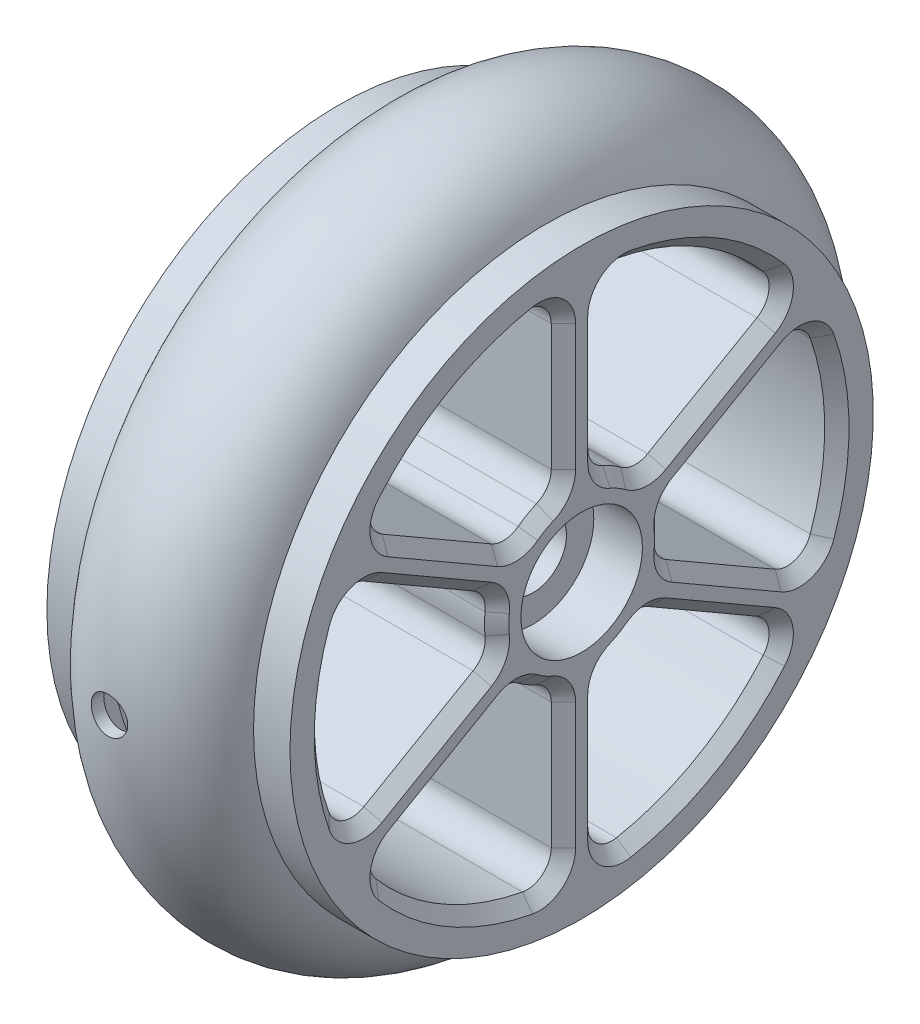
from build123d import *

# Parameters (mm, degrees)
CUT_EXTRUDE1_REACH = 22
SKETCH2_R          = 2.75
SKETCH3_R          = 5
CUT_EXTRUDE2_DEPTH = 4
SKETCH4_R          = 5
CUT_EXTRUDE3_DEPTH = 4
CUT_EXTRUDE4_REACH = 22
FILLET2_R          = 2
CHAMFER1_SIZE      = 1
CUT_EXTRUDE6_START = 5.94636
SKETCH9_R          = 1.5
CUT_EXTRUDE6_DEPTH = 8.05364
SKETCH7_R          = 5
CUT_EXTRUDE5_DEPTH = 0.5


with BuildPart() as part:
    # Sketch1 → Revolve1 (revolve)
    with BuildSketch(Plane.XY):
        with BuildLine():
            Line((-10, 24), (-10, 0))
            Line((-10, 0), (10, 0))
            Line((10, 0), (10, 24))
            Line((10, 24), (7, 24))
            ThreePointArc((7, 24), (0, 29), (-7, 24))
            Line((-7, 24), (-10, 24))
        make_face()
    revolve(axis=Axis((-29.685693942, 0, 0), (1, 0, 0)))

    # Sketch2 → Cut-Extrude1 (cut, up to next)
    with BuildSketch(Plane(origin=(10, 0, 0), x_dir=(0, 0, -1), z_dir=(1, 0, 0)), mode=Mode.PRIVATE) as cut_extrude1_sk1:
        Circle(SKETCH2_R)
    cut_extrude1_tool1 = extrude(cut_extrude1_sk1.sketch, amount=-CUT_EXTRUDE1_REACH, mode=Mode.PRIVATE) & part.part
    add(cut_extrude1_tool1.solids().sort_by_distance((10, 0, 0))[0], mode=Mode.SUBTRACT)

    # Sketch3 → Cut-Extrude2 (cut)
    with BuildSketch(Plane.ZY.offset(10)):
        Circle(SKETCH3_R)
    extrude(amount=-CUT_EXTRUDE2_DEPTH, mode=Mode.SUBTRACT)

    # Sketch4 → Cut-Extrude3 (cut)
    with BuildSketch(Plane(origin=(10, 0, 0), x_dir=(0, 0, -1), z_dir=(1, 0, 0))):
        Circle(SKETCH4_R)
    extrude(amount=-CUT_EXTRUDE3_DEPTH, mode=Mode.SUBTRACT)

    # Sketch5 → Cut-Extrude4 (cut, up to next)
    with BuildSketch(Plane(origin=(10, 0, 0), x_dir=(0, 0, -1), z_dir=(1, 0, 0)), mode=Mode.PRIVATE) as cut_extrude4_sk1:
        with BuildLine():
            Line((1.5, -6.837397166), (1.5, -20.946360066))
            ThreePointArc((1.5, -20.946360066), (10.5, -18.186533479), (17.390079934, -11.772218139))
            Line((17.390079934, -11.772218139), (5.171359641, -4.717736688))
            ThreePointArc((5.171359641, -4.717736688), (3.5, -6.062177826), (1.5, -6.837397166))
        make_face()
    cut_extrude4_tool1 = extrude(cut_extrude4_sk1.sketch, amount=-CUT_EXTRUDE4_REACH, mode=Mode.PRIVATE) & part.part
    add(cut_extrude4_tool1.solids().sort_by_distance((10, -12.993011, -7.501518))[0], mode=Mode.SUBTRACT)
    # Sketch5 → Cut-Extrude4 (cut, up to next)
    with BuildSketch(Plane(origin=(10, 0, 0), x_dir=(0, 0, -1), z_dir=(1, 0, 0)), mode=Mode.PRIVATE) as cut_extrude4_sk2:
        with BuildLine():
            Line((-1.5, -20.946360066), (-1.5, -6.837397166))
            ThreePointArc((-1.5, -6.837397166), (-3.5, -6.062177826), (-5.171359641, -4.717736688))
            Line((-5.171359641, -4.717736688), (-17.390079934, -11.772218139))
            ThreePointArc((-17.390079934, -11.772218139), (-10.5, -18.186533479), (-1.5, -20.946360066))
        make_face()
    cut_extrude4_tool2 = extrude(cut_extrude4_sk2.sketch, amount=-CUT_EXTRUDE4_REACH, mode=Mode.PRIVATE) & part.part
    add(cut_extrude4_tool2.solids().sort_by_distance((10, -12.993011, 7.501518))[0], mode=Mode.SUBTRACT)
    # Sketch5 → Cut-Extrude4 (cut, up to next)
    with BuildSketch(Plane(origin=(10, 0, 0), x_dir=(0, 0, -1), z_dir=(1, 0, 0)), mode=Mode.PRIVATE) as cut_extrude4_sk3:
        with BuildLine():
            Line((6.671359641, -2.119660477), (18.890079934, -9.174141927))
            ThreePointArc((18.890079934, -9.174141927), (21, 0), (18.890079934, 9.174141927))
            Line((18.890079934, 9.174141927), (6.671359641, 2.119660477))
            ThreePointArc((6.671359641, 2.119660477), (7, 0), (6.671359641, -2.119660477))
        make_face()
    cut_extrude4_tool3 = extrude(cut_extrude4_sk3.sketch, amount=-CUT_EXTRUDE4_REACH, mode=Mode.PRIVATE) & part.part
    add(cut_extrude4_tool3.solids().sort_by_distance((10, 0, -15.003037))[0], mode=Mode.SUBTRACT)
    # Sketch5 → Cut-Extrude4 (cut, up to next)
    with BuildSketch(Plane(origin=(10, 0, 0), x_dir=(0, 0, -1), z_dir=(1, 0, 0)), mode=Mode.PRIVATE) as cut_extrude4_sk4:
        with BuildLine():
            Line((-18.890079934, -9.174141927), (-6.671359641, -2.119660477))
            ThreePointArc((-6.671359641, -2.119660477), (-7, 0), (-6.671359641, 2.119660477))
            Line((-6.671359641, 2.119660477), (-18.890079934, 9.174141927))
            ThreePointArc((-18.890079934, 9.174141927), (-21, 0), (-18.890079934, -9.174141927))
        make_face()
    cut_extrude4_tool4 = extrude(cut_extrude4_sk4.sketch, amount=-CUT_EXTRUDE4_REACH, mode=Mode.PRIVATE) & part.part
    add(cut_extrude4_tool4.solids().sort_by_distance((10, 0, 15.003037))[0], mode=Mode.SUBTRACT)
    # Sketch5 → Cut-Extrude4 (cut, up to next)
    with BuildSketch(Plane(origin=(10, 0, 0), x_dir=(0, 0, -1), z_dir=(1, 0, 0)), mode=Mode.PRIVATE) as cut_extrude4_sk5:
        with BuildLine():
            ThreePointArc((-5.171359641, 4.717736688), (-3.5, 6.062177826), (-1.5, 6.837397166))
            Line((-1.5, 6.837397166), (-1.5, 20.946360066))
            ThreePointArc((-1.5, 20.946360066), (-10.5, 18.186533479), (-17.390079934, 11.772218139))
            Line((-17.390079934, 11.772218139), (-5.171359641, 4.717736688))
        make_face()
    cut_extrude4_tool5 = extrude(cut_extrude4_sk5.sketch, amount=-CUT_EXTRUDE4_REACH, mode=Mode.PRIVATE) & part.part
    add(cut_extrude4_tool5.solids().sort_by_distance((10, 12.993011, 7.501518))[0], mode=Mode.SUBTRACT)
    # Sketch5 → Cut-Extrude4 (cut, up to next)
    with BuildSketch(Plane(origin=(10, 0, 0), x_dir=(0, 0, -1), z_dir=(1, 0, 0)), mode=Mode.PRIVATE) as cut_extrude4_sk6:
        with BuildLine():
            Line((5.171359641, 4.717736688), (17.390079934, 11.772218139))
            ThreePointArc((17.390079934, 11.772218139), (10.5, 18.186533479), (1.5, 20.946360066))
            Line((1.5, 20.946360066), (1.5, 6.837397166))
            ThreePointArc((1.5, 6.837397166), (3.5, 6.062177826), (5.171359641, 4.717736688))
        make_face()
    cut_extrude4_tool6 = extrude(cut_extrude4_sk6.sketch, amount=-CUT_EXTRUDE4_REACH, mode=Mode.PRIVATE) & part.part
    add(cut_extrude4_tool6.solids().sort_by_distance((10, 12.993011, -7.501518))[0], mode=Mode.SUBTRACT)

    # Fillet2
    fillet2_edges = [part.edges().sort_by_distance(p)[0] for p in [
        (0, -11.772218139, 17.390079934),
        (0, -4.717736688, 5.171359641),
        (0, -6.837397166, 1.5),
        (0, -20.946360066, 1.5),
        (0, -20.946360066, -1.5),
        (0, -6.837397166, -1.5),
        (0, -4.717736688, -5.171359641),
        (0, -11.772218139, -17.390079934),
        (0, 11.772218139, -17.390079934),
        (0, 4.717736688, -5.171359641),
        (0, 6.837397166, -1.5),
        (0, 20.946360066, -1.5),
        (0, -9.174141927, -18.890079934),
        (0, -2.119660477, -6.671359641),
        (0, 2.119660477, -6.671359641),
        (0, 9.174141927, -18.890079934),
        (0, 9.174141927, 18.890079934),
        (0, 2.119660477, 6.671359641),
        (0, -2.119660477, 6.671359641),
        (0, -9.174141927, 18.890079934),
        (0, 20.946360066, 1.5),
        (0, 6.837397166, 1.5),
        (0, 4.717736688, 5.171359641),
        (0, 11.772218139, 17.390079934),
    ]]
    fillet(fillet2_edges, radius=FILLET2_R)

    # Chamfer1
    chamfer1_edges = [part.edges().sort_by_distance(p)[0] for p in [
        (10, 18.186533479, -10.5),
        (10, 8.040640949, -10.926798649),
        (10, 6.062177826, -3.5),
        (10, 13.483205686, -1.5),
        (10, 18.186533479, 10.5),
        (10, 13.483205686, 1.5),
        (10, 8.040640949, 10.926798649),
        (10, 6.062177826, 3.5),
        (10, 0, 21),
        (10, 5.442564738, 12.426798649),
        (10, -5.442564738, 12.426798649),
        (10, 0, 7),
        (10, -6.062177826, 3.5),
        (10, -13.483205686, 1.5),
        (10, -8.040640949, 10.926798649),
        (10, -18.186533479, 10.5),
        (10, -18.186533479, -10.5),
        (10, -13.483205686, -1.5),
        (10, -8.040640949, -10.926798649),
        (10, -6.062177826, -3.5),
        (10, -5.442564738, -12.426798649),
        (10, 0, -7),
        (10, 5.442564738, -12.426798649),
        (10, 0, -21),
        (10, 12.031794768, -16.394345338),
        (10, 5.18072343, -5.306609534),
        (10, 7.186020379, -1.833333333),
        (10, 20.213816925, -2.222667253),
        (10, 20.213816925, 2.222667253),
        (10, 12.031794768, 16.394345338),
        (10, 5.18072343, 5.306609534),
        (10, 7.186020379, 1.833333333),
        (10, 8.182022158, 18.617012591),
        (10, -8.182022158, 18.617012591),
        (10, -2.005296949, 7.139942867),
        (10, 2.005296949, 7.139942867),
        (10, -7.186020379, 1.833333333),
        (10, -5.18072343, 5.306609534),
        (10, -12.031794768, 16.394345338),
        (10, -20.213816925, 2.222667253),
        (10, -20.213816925, -2.222667253),
        (10, -12.031794768, -16.394345338),
        (10, -5.18072343, -5.306609534),
        (10, -7.186020379, -1.833333333),
        (10, -2.005296949, -7.139942867),
        (10, 2.005296949, -7.139942867),
        (10, 8.182022158, -18.617012591),
        (10, -8.182022158, -18.617012591),
    ]]
    chamfer(chamfer1_edges, length=CHAMFER1_SIZE)

    # Sketch8 → Cut-Revolve1 (revolve, cut)
    with BuildSketch(Plane.XY):
        with BuildLine():
            ThreePointArc((6, 23.827105745), (0, 28), (-6, 23.827105745))
            Line((-6, 23.827105745), (-6, 22.827105745))
            Line((-6, 22.827105745), (6, 22.827105745))
            Line((6, 22.827105745), (6, 23.827105745))
        make_face()
    revolve(axis=Axis((-25.031120021, 0, 0), (1, 0, 0)), mode=Mode.SUBTRACT)

    # Sketch9 → Cut-Extrude6 (cut)
    with BuildSketch(Plane.XY.offset(15).offset(CUT_EXTRUDE6_START)):
        Circle(SKETCH9_R)
    cut_extrude6 = extrude(amount=CUT_EXTRUDE6_DEPTH, mode=Mode.SUBTRACT)

    # Mirror1: Cut-Extrude6 across plane
    add(cut_extrude6.mirror(Plane.XY), mode=Mode.SUBTRACT)

    # Sketch7 → Cut-Extrude5 (cut)
    with BuildSketch(Plane.ZY.offset(6)):
        Circle(SKETCH7_R)
    extrude(amount=-CUT_EXTRUDE5_DEPTH, mode=Mode.SUBTRACT)


solid = part.part
